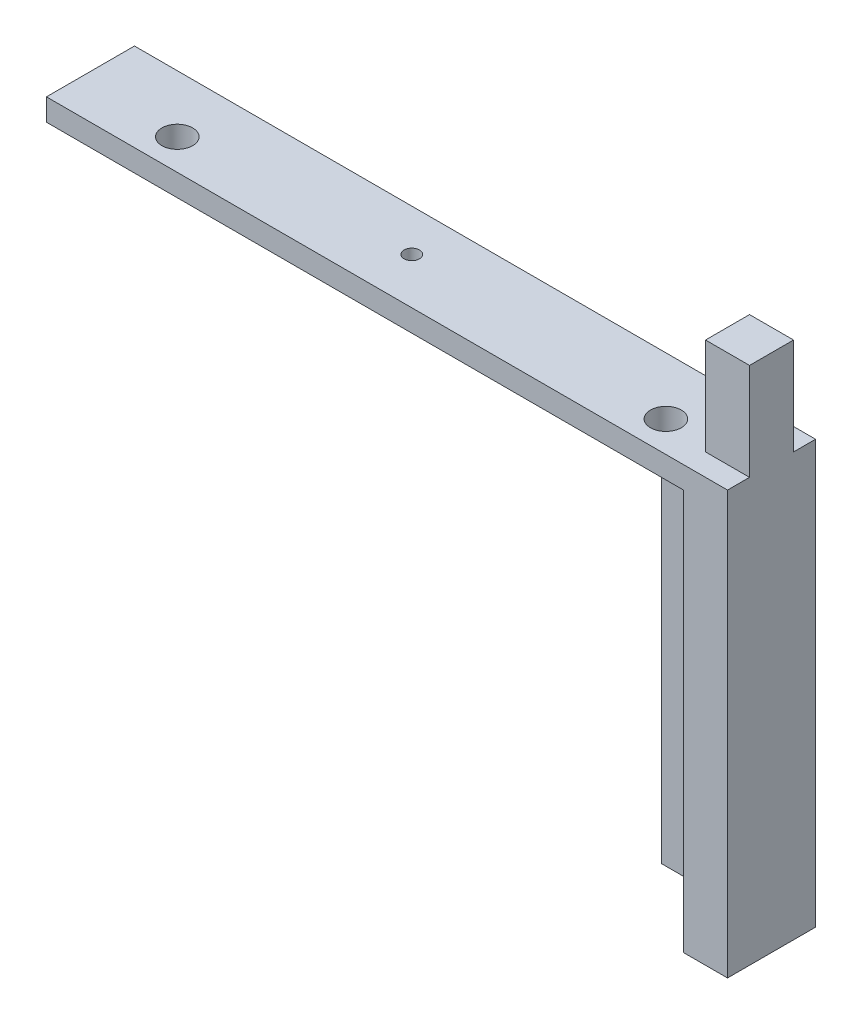
from build123d import *

# Parameters (mm, degrees)
BOSS_EXTRUDE3_DEPTH     = 10
SKETCH4_W               = 30
SKETCH4_H               = 25
BOSS_EXTRUDE4_DEPTH     = 5
BOSS_EXTRUDE5_DEPTH     = 5
BOSS_EXTRUDE6_DEPTH     = 71
BOSS_EXTRUDE7_DEPTH     = 124.720470612
SKETCH9_R               = 3.25
CUT_EXTRUDE1_DEPTH      = 15
SKETCH13_R              = 1.75
CUT_EXTRUDE2_DEPTH      = 8
CUT_EXTRUDE2_DEPTH_BACK = 10
SKETCH14_R              = 3.5
CUT_EXTRUDE3_DEPTH      = 8
CUT_EXTRUDE3_DEPTH_BACK = 12
SKETCH15_R              = 3.5
CUT_EXTRUDE4_DEPTH      = 4
CUT_EXTRUDE4_DEPTH_BACK = 17


with BuildPart() as part:
    # Sketch3 → Boss-Extrude3 (new body)
    with BuildSketch(Plane.XY):
        Polygon((0, 0), (0, -5), (20, -5), (20, -25), (30, -25), (30, 22.02), (20, 22.02), (20, 0), align=None)
    extrude(amount=BOSS_EXTRUDE3_DEPTH)

    # Sketch4 → Boss-Extrude4 (add)
    with BuildSketch(Plane(origin=(0, 0, 0), x_dir=(-1, 0, 0), z_dir=(0, 0, -1))):
        with Locations((-15, -12.5)):
            Rectangle(SKETCH4_W, SKETCH4_H)
    extrude(amount=BOSS_EXTRUDE4_DEPTH)

    # Sketch5 → Boss-Extrude5 (add)
    with BuildSketch(Plane.XY.offset(10)):
        Polygon((0, 0), (0, -5), (20, -5), (20, -25), (30, -25), (30, 0), align=None)
    extrude(amount=BOSS_EXTRUDE5_DEPTH)

    # Sketch6 → Boss-Extrude6 (add)
    with BuildSketch(Plane.XZ.offset(25)):
        Polygon((20, 15), (20, 0), (0, 0), (0, -5), (30, -5), (30, 15), align=None)
    extrude(amount=BOSS_EXTRUDE6_DEPTH)

    # Sketch7 → Boss-Extrude7 (add)
    with BuildSketch(Plane.ZY):
        Polygon((15, -5), (15, 0), (0, 0), (-5, 0), (-5, -5), (-5, -9.319004474), (0, -9.319004474), (0, -5), align=None)
    extrude(amount=BOSS_EXTRUDE7_DEPTH)

    # Sketch9 → Cut-Extrude1 (cut)
    with BuildSketch(Plane(origin=(0, 0, -5), x_dir=(-1, 0, 0), z_dir=(0, 0, -1))):
        with Locations((-13, -15)):
            Circle(SKETCH9_R)
    extrude(amount=-CUT_EXTRUDE1_DEPTH, mode=Mode.SUBTRACT)

    # Sketch13 → Cut-Extrude2 (cut, two sides)
    with BuildSketch(Plane(origin=(0, 0, 0), x_dir=(1, 0, 0), z_dir=(0, 1, 0))) as cut_extrude2_sk:
        with Locations((-52.220470612, -4.500931244)):
            Circle(SKETCH13_R)
    extrude(amount=CUT_EXTRUDE2_DEPTH, mode=Mode.SUBTRACT)
    extrude(cut_extrude2_sk.sketch, amount=-CUT_EXTRUDE2_DEPTH_BACK, mode=Mode.SUBTRACT)

    # Sketch14 → Cut-Extrude3 (cut, two sides)
    with BuildSketch(Plane(origin=(0, 0, 0), x_dir=(1, 0, 0), z_dir=(0, 1, 0))) as cut_extrude3_sk:
        with Locations((-102, -8)):
            Circle(SKETCH14_R)
    extrude(amount=CUT_EXTRUDE3_DEPTH, mode=Mode.SUBTRACT)
    extrude(cut_extrude3_sk.sketch, amount=-CUT_EXTRUDE3_DEPTH_BACK, mode=Mode.SUBTRACT)

    # Sketch15 → Cut-Extrude4 (cut, two sides)
    with BuildSketch(Plane(origin=(0, 0, 0), x_dir=(1, 0, 0), z_dir=(0, 1, 0))) as cut_extrude4_sk:
        with Locations((9, -8)):
            Circle(SKETCH15_R)
    extrude(amount=CUT_EXTRUDE4_DEPTH, mode=Mode.SUBTRACT)
    extrude(cut_extrude4_sk.sketch, amount=-CUT_EXTRUDE4_DEPTH_BACK, mode=Mode.SUBTRACT)


solid = part.part
